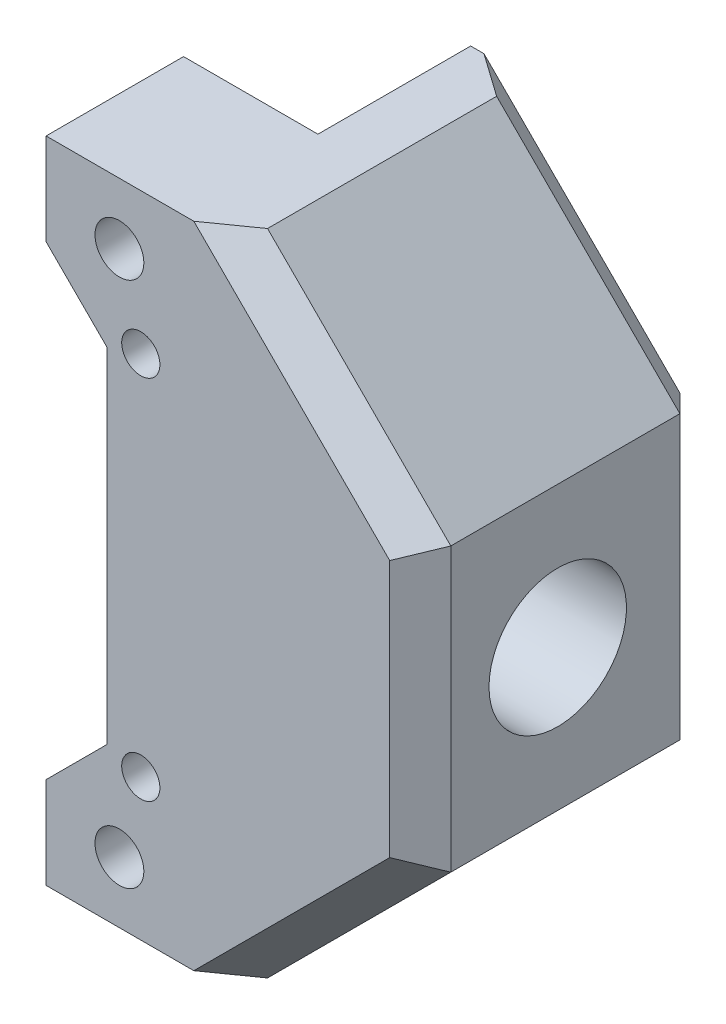
from build123d import *

# Parameters (mm, degrees)
ESQUISSE1_R                               = 1.6
BOSS_EXTRU_1_DEPTH                        = 9
ESQUISSE2_W                               = 15.7
ESQUISSE2_H                               = 42.5
BOSS_EXTRU_2_DEPTH                        = 19
ESQUISSE4_R                               = 6
ENL_V_MAT_EXTRU_1_DEPTH                   = 4.8
ENL_V_MAT_EXTRU_2_DEPTH                   = 5
ESQUISSE6_R                               = 4.5
ENL_V_MAT_EXTRU_3_DEPTH                   = 11.7
CHANFREIN1_SIZE                           = 12
CHANFREIN2_SIZE                           = 2
TROU_POUR_TARAUDAGE_POUR_TROU_TARAUD_M3_D = 2.5


with BuildPart() as part:
    # Esquisse1 → Boss.-Extru.1 (new body)
    with BuildSketch(Plane.XY):
        Polygon((38.615489841, 27.25), (38.615489841, 15.25), (38.615489841, 0), (29.815489841, 0), (29.815489841, 6), (33.815489841, 10), (33.815489841, 15.25), (33.815489841, 27.25), (33.815489841, 32.5), (29.815489841, 36.5), (29.815489841, 42.5), (38.615489841, 42.5), align=None)
        with Locations((34.615489841, 4)):
            Circle(ESQUISSE1_R, mode=Mode.SUBTRACT)
        with Locations((34.615489841, 38.5)):
            Circle(ESQUISSE1_R, mode=Mode.SUBTRACT)
    extrude(amount=BOSS_EXTRU_1_DEPTH)

    # Esquisse2 → Boss.-Extru.2 (add)
    with BuildSketch(Plane.XY.offset(9)):
        with Locations((46.465489841, 21.25)):
            Rectangle(ESQUISSE2_W, ESQUISSE2_H)
    extrude(amount=-BOSS_EXTRU_2_DEPTH)

    # Esquisse4 → Enlèv. mat.-Extru.1 (cut)
    with BuildSketch(Plane.ZY.offset(-33.815489841)):
        with Locations((0, 21.25)):
            Circle(ESQUISSE4_R)
    extrude(amount=-ENL_V_MAT_EXTRU_1_DEPTH, mode=Mode.SUBTRACT)

    # Esquisse5 → Enlèv. mat.-Extru.2 (cut)
    with BuildSketch(Plane.ZY.offset(-38.615489841)):
        with BuildLine():
            Line((0, 29.25), (-10, 29.25))
            Line((-10, 29.25), (-10, 13.25))
            Line((-10, 13.25), (0, 13.25))
            ThreePointArc((0, 13.25), (8, 21.25), (0, 29.25))
        make_face()
    extrude(amount=-ENL_V_MAT_EXTRU_2_DEPTH, mode=Mode.SUBTRACT)

    # Esquisse6 → Enlèv. mat.-Extru.3 (cut, through all)
    with BuildSketch(Plane.ZY.offset(-43.615489841)):
        with Locations((0, 21.25)):
            Circle(ESQUISSE6_R)
    extrude(amount=-ENL_V_MAT_EXTRU_3_DEPTH, mode=Mode.SUBTRACT)

    # Chanfrein1
    chanfrein1_edges = [part.edges().sort_by_distance(p)[0] for p in [
        (54.315489841, 0, -0.5),
        (54.315489841, 42.5, -0.5),
    ]]
    chamfer(chanfrein1_edges, length=CHANFREIN1_SIZE)

    # Chanfrein2
    chanfrein2_edges = [part.edges().sort_by_distance(p)[0] for p in [
        (54.315489841, 21.25, -10),
        (54.315489841, 21.25, 9),
        (48.315489841, 6, 9),
        (48.315489841, 36.5, 9),
        (48.315489841, 6, -10),
        (48.315489841, 36.5, -10),
    ]]
    chamfer(chanfrein2_edges, length=CHANFREIN2_SIZE)

    # Trou pour taraudage pour trou taraudé M31 (through all)
    with Locations(Plane.XY.offset(9)):
        with Locations((36.015489841, 33.25), (36.015489841, 9.25)):
            Hole(TROU_POUR_TARAUDAGE_POUR_TROU_TARAUD_M3_D / 2)


solid = part.part
